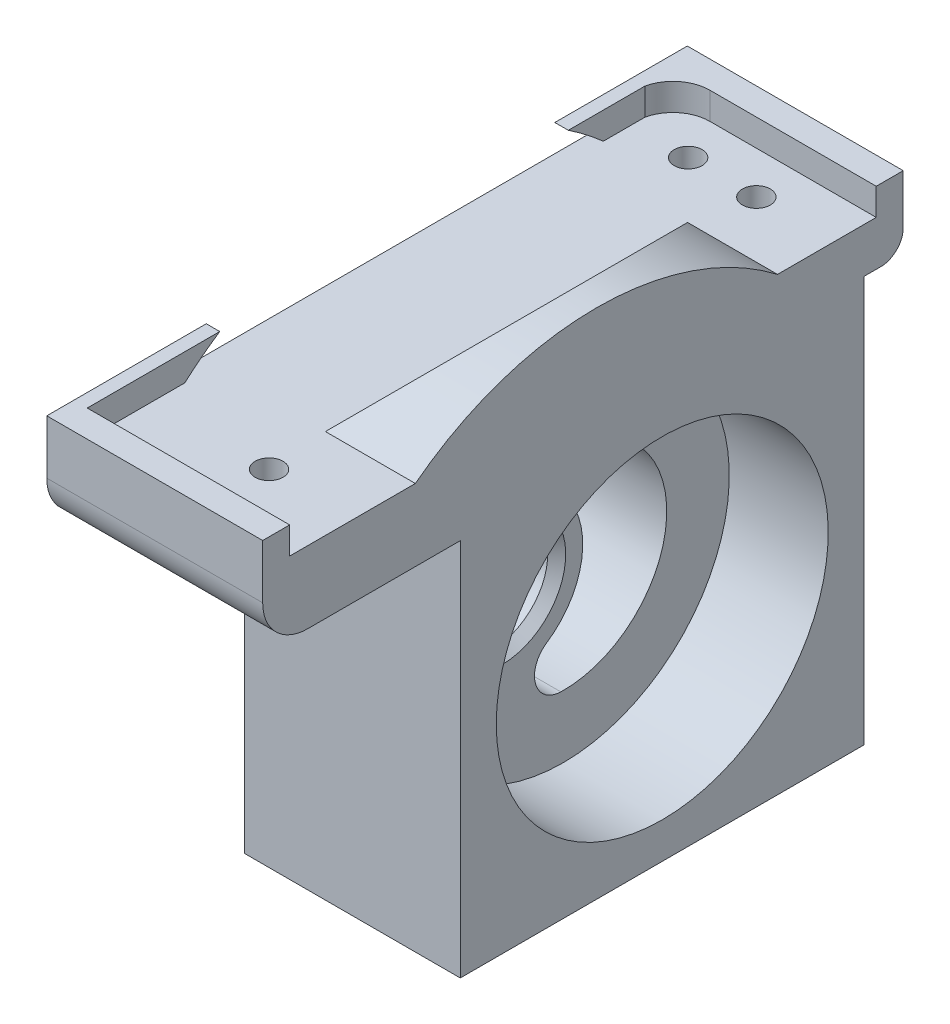
from build123d import *

# Parameters (mm, degrees)
SKETCH1_R           = 22.45
SKETCH1_R_2         = 18.45
SKETCH1_R_3         = 6.11
SKETCH1_R_4         = 5.25
SKETCH1_R_5         = 3.075
BOSS_EXTRUDE1_DEPTH = 5.5
SKETCH1_3_R         = 22.45
SKETCH1_3_R_2       = 18.45
SKETCH1_3_R_3       = 6.11
BOSS_EXTRUDE2_DEPTH = 6
BOSS_EXTRUDE3_START = -6
SKETCH1_4_R         = 22.45
SKETCH1_4_R_2       = 18.45
BOSS_EXTRUDE3_DEPTH = 11
BOSS_EXTRUDE4_DEPTH = 10
DRAFT1_ANGLE        = 45
BOSS_EXTRUDE5_DEPTH = 3
SKETCH4_R           = 3.075
BOSS_EXTRUDE6_DEPTH = 1.5
CUT_EXTRUDE1_START  = -11
SKETCH3_3_R         = 1.55
CUT_EXTRUDE1_DEPTH  = 11
CUT_EXTRUDE2_START  = -9.6
SKETCH3_4_R         = 1.55
CUT_EXTRUDE2_DEPTH  = 2.6
CUT_EXTRUDE3_START  = -8
SKETCH3_5_R         = 1.55
CUT_EXTRUDE3_DEPTH  = 2.5
CUT_EXTRUDE4_DEPTH  = 13
CHAMFER1_SIZE       = 1


with BuildPart() as part:
    # Sketch1 → Boss-Extrude1 (new body)
    with BuildSketch(Plane.ZY.offset(50.650222499)):
        with Locations((41.541684016, -24.712638018)):
            Circle(SKETCH1_R)
        with Locations((41.541684016, -24.712638018)):
            Circle(SKETCH1_R_2, mode=Mode.SUBTRACT)
        with Locations((41.541684016, -24.712638018)):
            Circle(SKETCH1_R_2)
        with Locations((48.379176073, -23.213070625)):
            Circle(SKETCH1_R_3, mode=Mode.SUBTRACT)
        with Locations((48.379176073, -23.213070625)):
            Circle(SKETCH1_R_3)
        with Locations((48.379176073, -23.213070625)):
            Circle(SKETCH1_R_4, mode=Mode.SUBTRACT)
        with Locations((48.379176073, -23.213070625)):
            Circle(SKETCH1_R_4)
        with Locations((48.379176073, -23.213070625)):
            Circle(SKETCH1_R_5, mode=Mode.SUBTRACT)
        with BuildLine():
            Line((19.091684016, -24.712638018), (19.091684016, -47.162638018))
            Line((19.091684016, -47.162638018), (41.54168412, -47.162638018))
            ThreePointArc((41.54168412, -47.162638018), (25.667136815, -40.587185293), (19.091684016, -24.712638018))
        make_face()
        with BuildLine():
            ThreePointArc((63.991684016, -24.712638018), (57.41623129, -40.587185219), (41.54168412, -47.162638018))
            Line((41.54168412, -47.162638018), (63.991684016, -47.162638018))
            Line((63.991684016, -47.162638018), (63.991684016, -24.712638018))
        make_face()
        with BuildLine():
            Line((19.091684016, -2.062638018), (19.091684016, -24.712638018))
            ThreePointArc((19.091684016, -24.712638018), (41.541684016, -2.262638018), (63.991684016, -24.712638018))
            Line((63.991684016, -24.712638018), (63.991684016, -5.062638018))
            Line((63.991684016, -5.062638018), (80.954804088, -5.062638018))
            ThreePointArc((80.954804088, -5.062638018), (84.490337994, -3.598171924), (85.954804088, -0.062638018))
            Line((85.954804088, -0.062638018), (85.954804088, 5.937361982))
            Line((85.954804088, 5.937361982), (82.954804088, 5.937361982))
            Line((82.954804088, 5.937361982), (82.954804088, 2.937361982))
            Line((82.954804088, 2.937361982), (17.754804088, 2.937361982))
            Line((17.754804088, 2.937361982), (17.754804088, 5.937361982))
            Line((17.754804088, 5.937361982), (14.754804088, 5.937361982))
            Line((14.754804088, 5.937361982), (14.754804088, 0.437361982))
            ThreePointArc((14.754804088, 0.437361982), (15.487037135, -1.330404971), (17.254804088, -2.062638018))
            Line((17.254804088, -2.062638018), (19.091684016, -2.062638018))
        make_face()
    extrude(amount=BOSS_EXTRUDE1_DEPTH)

    # Sketch1_3 → Boss-Extrude2 (add)
    with BuildSketch(Plane.ZY.offset(50.650222499)):
        with Locations((41.541684016, -24.712638018)):
            Circle(SKETCH1_3_R)
        with Locations((41.541684016, -24.712638018)):
            Circle(SKETCH1_3_R_2, mode=Mode.SUBTRACT)
        with Locations((41.541684016, -24.712638018)):
            Circle(SKETCH1_3_R_2)
        with Locations(Location((48.379176073, -23.213070625, 0), (0, 0, 270))):
            Circle(SKETCH1_3_R_3, mode=Mode.SUBTRACT)
        with BuildLine():
            Line((19.091684016, -24.712638018), (19.091684016, -47.162638018))
            Line((19.091684016, -47.162638018), (41.54168412, -47.162638018))
            ThreePointArc((41.54168412, -47.162638018), (25.667136815, -40.587185293), (19.091684016, -24.712638018))
        make_face()
        with BuildLine():
            ThreePointArc((63.991684016, -24.712638018), (57.41623129, -40.587185219), (41.54168412, -47.162638018))
            Line((41.54168412, -47.162638018), (63.991684016, -47.162638018))
            Line((63.991684016, -47.162638018), (63.991684016, -24.712638018))
        make_face()
        with BuildLine():
            Line((19.091684016, -2.062638018), (19.091684016, -24.712638018))
            ThreePointArc((19.091684016, -24.712638018), (41.541684016, -2.262638018), (63.991684016, -24.712638018))
            Line((63.991684016, -24.712638018), (63.991684016, -5.062638018))
            Line((63.991684016, -5.062638018), (80.954804088, -5.062638018))
            ThreePointArc((80.954804088, -5.062638018), (84.490337994, -3.598171924), (85.954804088, -0.062638018))
            Line((85.954804088, -0.062638018), (85.954804088, 5.937361982))
            Line((85.954804088, 5.937361982), (82.954804088, 5.937361982))
            Line((82.954804088, 5.937361982), (82.954804088, 2.937361982))
            Line((82.954804088, 2.937361982), (17.754804088, 2.937361982))
            Line((17.754804088, 2.937361982), (17.754804088, 5.937361982))
            Line((17.754804088, 5.937361982), (14.754804088, 5.937361982))
            Line((14.754804088, 5.937361982), (14.754804088, 0.437361982))
            ThreePointArc((14.754804088, 0.437361982), (15.487037135, -1.330404971), (17.254804088, -2.062638018))
            Line((17.254804088, -2.062638018), (19.091684016, -2.062638018))
        make_face()
    extrude(amount=-BOSS_EXTRUDE2_DEPTH)

    # Sketch1_4 → Boss-Extrude3 (add)
    with BuildSketch(Plane.ZY.offset(50.650222499).offset(BOSS_EXTRUDE3_START)):
        with BuildLine():
            Line((19.091684016, -24.712638018), (19.091684016, -47.162638018))
            Line((19.091684016, -47.162638018), (41.54168412, -47.162638018))
            ThreePointArc((41.54168412, -47.162638018), (25.667136815, -40.587185293), (19.091684016, -24.712638018))
        make_face()
        with BuildLine():
            ThreePointArc((63.991684016, -24.712638018), (57.41623129, -40.587185219), (41.54168412, -47.162638018))
            Line((41.54168412, -47.162638018), (63.991684016, -47.162638018))
            Line((63.991684016, -47.162638018), (63.991684016, -24.712638018))
        make_face()
        with Locations((41.541684016, -24.712638018)):
            Circle(SKETCH1_4_R)
        with Locations(Location((41.541684016, -24.712638018, 0), (0, 0, 270))):
            Circle(SKETCH1_4_R_2, mode=Mode.SUBTRACT)
        with BuildLine():
            Line((19.091684016, -2.062638018), (19.091684016, -24.712638018))
            ThreePointArc((19.091684016, -24.712638018), (41.541684016, -2.262638018), (63.991684016, -24.712638018))
            Line((63.991684016, -24.712638018), (63.991684016, -5.062638018))
            Line((63.991684016, -5.062638018), (80.954804088, -5.062638018))
            ThreePointArc((80.954804088, -5.062638018), (84.490337994, -3.598171924), (85.954804088, -0.062638018))
            Line((85.954804088, -0.062638018), (85.954804088, 5.937361982))
            Line((85.954804088, 5.937361982), (82.954804088, 5.937361982))
            Line((82.954804088, 5.937361982), (82.954804088, 2.937361982))
            Line((82.954804088, 2.937361982), (17.754804088, 2.937361982))
            Line((17.754804088, 2.937361982), (17.754804088, 5.937361982))
            Line((17.754804088, 5.937361982), (14.754804088, 5.937361982))
            Line((14.754804088, 5.937361982), (14.754804088, 0.437361982))
            ThreePointArc((14.754804088, 0.437361982), (15.487037135, -1.330404971), (17.254804088, -2.062638018))
            Line((17.254804088, -2.062638018), (19.091684016, -2.062638018))
        make_face()
    extrude(amount=-BOSS_EXTRUDE3_DEPTH)

    # Sketch2 → Boss-Extrude4 (add)
    with BuildSketch(Plane(origin=(-33.650222499, 0, 0), x_dir=(0, 0, -1), z_dir=(1, 0, 0))):
        with BuildLine():
            Line((-68.983263405, 2.937361982), (-28.72634477, 2.937361982))
            ThreePointArc((-28.72634477, 2.937361982), (-48.854804088, 9.786929375), (-68.983263405, 2.937361982))
        make_face()
    extrude(amount=-BOSS_EXTRUDE4_DEPTH)

    # Draft1
    draft1_faces = [part.faces().sort_by_distance(p)[0] for p in [
        (-43.650222499, 5.703123898, 48.854804088),
    ]]
    draft(draft1_faces, Plane(origin=(-144.97054675, 2.937361982, 0), x_dir=(1, 0, 0), z_dir=(0, 1, 0)), DRAFT1_ANGLE)

    # Sketch3 → Boss-Extrude5 (add)
    with BuildSketch(Plane(origin=(0, 2.937361982, 0), x_dir=(1, 0, 0), z_dir=(0, 1, 0))):
        with BuildLine():
            ThreePointArc((-56.150222499, -20.954804088), (-54.711472194, -18.653241969), (-52.150222499, -17.754804088))
            Line((-52.150222499, -17.754804088), (-56.150222499, -17.754804088))
            Line((-56.150222499, -17.754804088), (-56.150222499, -20.954804088))
        make_face()
    extrude(amount=BOSS_EXTRUDE5_DEPTH)

    # Sketch4 → Boss-Extrude6 (add)
    with BuildSketch(Plane.ZY.offset(56.150222499)):
        with BuildLine():
            Line((20.954804088, 2.937361982), (20.954804088, 5.937361982))
            Line((20.954804088, 5.937361982), (14.754804088, 5.937361982))
            Line((14.754804088, 5.937361982), (14.754804088, 0.437361982))
            ThreePointArc((14.754804088, 0.437361982), (15.487037135, -1.330404971), (17.254804088, -2.062638018))
            Line((17.254804088, -2.062638018), (19.091684016, -2.062638018))
            Line((19.091684016, -2.062638018), (19.091684016, -47.162638018))
            Line((19.091684016, -47.162638018), (63.991684016, -47.162638018))
            Line((63.991684016, -47.162638018), (63.991684016, -5.062638018))
            Line((63.991684016, -5.062638018), (80.954804088, -5.062638018))
            ThreePointArc((80.954804088, -5.062638018), (84.490337994, -3.598171924), (85.954804088, -0.062638018))
            Line((85.954804088, -0.062638018), (85.954804088, 5.937361982))
            Line((85.954804088, 5.937361982), (82.954804088, 5.937361982))
            Line((82.954804088, 5.937361982), (82.954804088, 2.937361982))
            Line((82.954804088, 2.937361982), (72.117539836, 2.937361982))
            Line((72.117539836, 2.937361982), (25.59206834, 2.937361982))
            Line((25.59206834, 2.937361982), (20.954804088, 2.937361982))
        make_face()
        with Locations((48.379176073, -23.213070625)):
            Circle(SKETCH4_R, mode=Mode.SUBTRACT)
        with BuildLine():
            Line((29.48337464, 5.937361982), (20.954804088, 5.937361982))
            Line((20.954804088, 5.937361982), (20.954804088, 2.937361982))
            Line((20.954804088, 2.937361982), (25.59206834, 2.937361982))
            ThreePointArc((25.59206834, 2.937361982), (27.485012079, 4.505731469), (29.48337464, 5.937361982))
        make_face()
        with BuildLine():
            ThreePointArc((68.226233536, 5.937361982), (70.224596096, 4.505731469), (72.117539836, 2.937361982))
            Line((72.117539836, 2.937361982), (82.954804088, 2.937361982))
            Line((82.954804088, 2.937361982), (82.954804088, 5.937361982))
            Line((82.954804088, 5.937361982), (68.226233536, 5.937361982))
        make_face()
    extrude(amount=BOSS_EXTRUDE6_DEPTH)

    # Sketch3_3 → Cut-Extrude1 (cut)
    with BuildSketch(Plane(origin=(0, 2.937361982, 0), x_dir=(1, 0, 0), z_dir=(0, 1, 0)).offset(CUT_EXTRUDE1_START)):
        with Locations(Location((-49.859325965, -22.454804088, 0), (0, 0, 180))):
            Circle(SKETCH3_3_R)
        with Locations(Location((-42.277532896, -22.454804088, 0), (0, 0, 180))):
            Circle(SKETCH3_3_R)
        with Locations(Location((-43.150222499, -75.748357954, 0), (0, 0, 180))):
            Circle(SKETCH3_3_R)
    extrude(amount=CUT_EXTRUDE1_DEPTH, mode=Mode.SUBTRACT)

    # Sketch3_4 → Cut-Extrude2 (cut)
    with BuildSketch(Plane(origin=(0, 2.937361982, 0), x_dir=(1, 0, 0), z_dir=(0, 1, 0)).offset(CUT_EXTRUDE2_START)):
        Polygon((-45.127532896, -20.809355821), (-45.127532896, -24.100252355), (-42.277532896, -25.745700622), (-39.427532896, -24.100252355), (-39.427532896, -20.809355821), (-42.277532896, -19.163907553), align=None)
        with Locations(Location((-42.277532896, -22.454804088, 0), (0, 0, 180))):
            Circle(SKETCH3_4_R, mode=Mode.SUBTRACT)
        Polygon((-52.709325965, -20.809355821), (-52.709325965, -24.100252355), (-49.859325965, -25.745700622), (-47.009325965, -24.100252355), (-47.009325965, -20.809355821), (-49.859325965, -19.163907553), align=None)
        with Locations(Location((-49.859325965, -22.454804088, 0), (0, 0, 180))):
            Circle(SKETCH3_4_R, mode=Mode.SUBTRACT)
        Polygon((-47.009325965, -19.091684016), (-47.009325965, -20.809355821), (-49.859325965, -19.163907553), (-52.709325965, -20.809355821), (-52.709325965, -19.091684016), align=None)
        Polygon((-39.427532896, -19.091684016), (-39.427532896, -20.809355821), (-42.277532896, -19.163907553), (-45.127532896, -20.809355821), (-45.127532896, -19.091684016), align=None)
    extrude(amount=CUT_EXTRUDE2_DEPTH, mode=Mode.SUBTRACT)

    # Sketch3_5 → Cut-Extrude3 (cut)
    with BuildSketch(Plane(origin=(0, 2.937361982, 0), x_dir=(1, 0, 0), z_dir=(0, 1, 0)).offset(CUT_EXTRUDE3_START)):
        Polygon((-44.795670766, -78.598357954), (-41.504774232, -78.598357954), (-39.859325965, -75.748357954), (-41.504774232, -72.898357954), (-44.795670766, -72.898357954), (-46.441119034, -75.748357954), align=None)
        with Locations(Location((-43.150222499, -75.748357954, 0), (0, 0, 180))):
            Circle(SKETCH3_5_R, mode=Mode.SUBTRACT)
    extrude(amount=CUT_EXTRUDE3_DEPTH, mode=Mode.SUBTRACT)

    # Sketch5 → Cut-Extrude4 (cut)
    with BuildSketch(Plane.ZY.offset(57.650222499)):
        with BuildLine():
            ThreePointArc((40.720112365, -18.486682668), (40.436145171, -14.9487232), (36.976058346, -14.157778368))
            ThreePointArc((36.976058346, -14.157778368), (30.30866135, -27.176213022), (41.812330431, -36.209452817))
            ThreePointArc((41.812330431, -36.209452817), (44.623826058, -34.043053291), (43.401089282, -30.710980461))
            ThreePointArc((43.401089282, -30.710980461), (39.588114857, -25.141085845), (40.720112365, -18.486682668))
        make_face()
    extrude(amount=-CUT_EXTRUDE4_DEPTH, mode=Mode.SUBTRACT)

    # Chamfer1
    chamfer1_edges = [part.edges().sort_by_distance(p)[0] for p in [
        (-44.650222499, -17.103070625, 48.379176073),
    ]]
    chamfer(chamfer1_edges, length=CHAMFER1_SIZE)


solid = part.part
